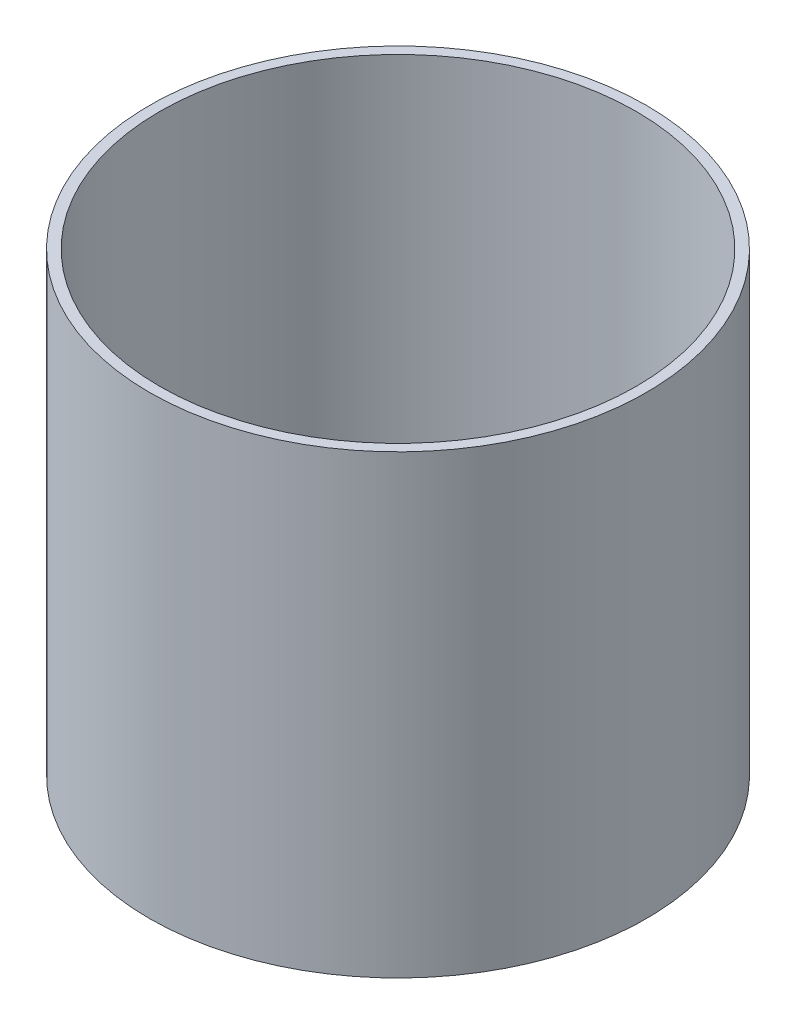
from build123d import *

# Parameters (mm, degrees)
SKETCH1_R           = 152.4
SKETCH1_R_2         = 146.05
BOSS_EXTRUDE1_DEPTH = 279.4


with BuildPart() as part:
    # Sketch1 → Boss-Extrude1 (new body)
    with BuildSketch(Plane(origin=(0, 0, 0), x_dir=(1, 0, 0), z_dir=(0, 1, 0))):
        Circle(SKETCH1_R)
        Circle(SKETCH1_R_2, mode=Mode.SUBTRACT)
    extrude(amount=BOSS_EXTRUDE1_DEPTH)


solid = part.part
